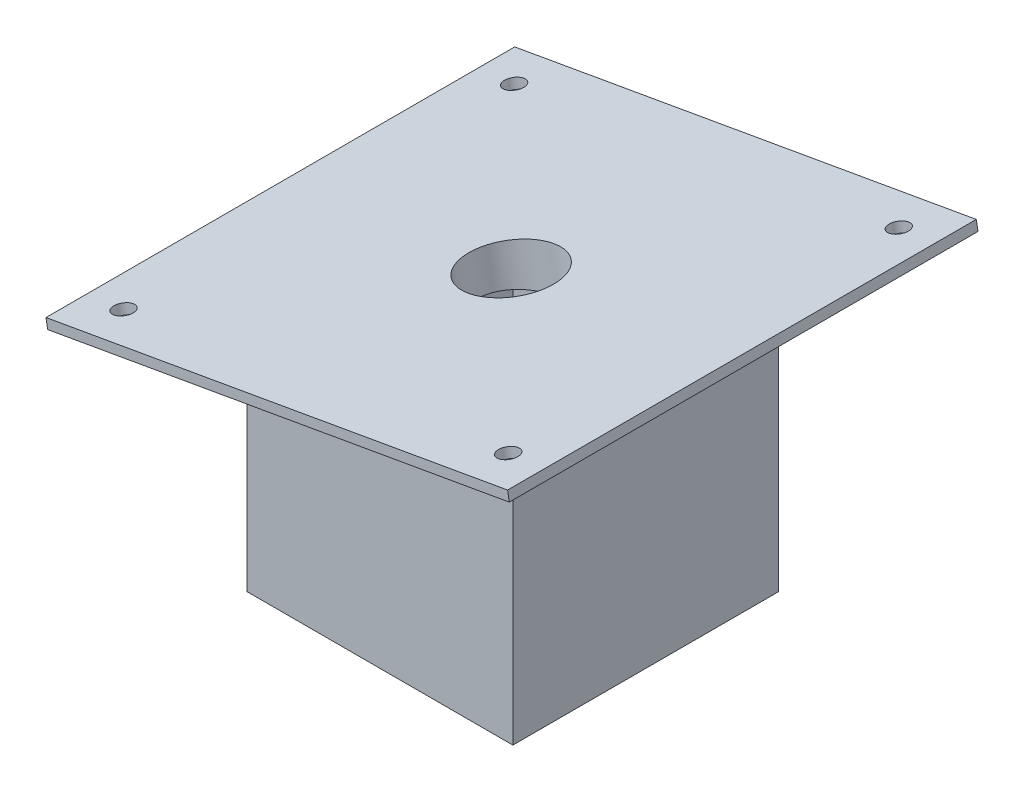
from build123d import *

# Parameters (mm, degrees)
SKETCH1_W                       = 86.36
SKETCH1_H                       = 86.36
BOSS_EXTRUDE1_DEPTH             = 95.25
SKETCH2_W                       = 78.74
SKETCH2_H                       = 78.74
CUT_EXTRUDE1_DEPTH              = 76.2
CUT_EXTRUDE2_DEPTH              = 87.36
SKETCH7_W                       = 152.4
SKETCH7_H                       = 152.4
BOSS_EXTRUDE2_DEPTH             = 3.175
SKETCH9_R                       = 13.97
CUT_EXTRUDE4_DEPTH              = 103.510777623
F_1_4_0_25_DIAMETER_HOLE1_D     = 6.35
F_1_4_0_25_DIAMETER_HOLE1_DEPTH = 3.175
F_1_4_0_25_DIAMETER_HOLE1_TIP   = 1.907732465


with BuildPart() as part:
    # Sketch1 → Boss-Extrude1 (new body)
    with BuildSketch(Plane(origin=(0, 0, 0), x_dir=(1, 0, 0), z_dir=(0, 1, 0))):
        Rectangle(SKETCH1_W, SKETCH1_H)
    extrude(amount=BOSS_EXTRUDE1_DEPTH)

    # Sketch2 → Cut-Extrude1 (cut)
    with BuildSketch(Plane(origin=(0, 0, 0), x_dir=(-1, 0, 0), z_dir=(0, -1, 0))):
        Rectangle(SKETCH2_W, SKETCH2_H)
    extrude(amount=-CUT_EXTRUDE1_DEPTH, mode=Mode.SUBTRACT)

    # Sketch4 → Cut-Extrude2 (cut, through all)
    with BuildSketch(Plane(origin=(0, 0, -43.18), x_dir=(-1, 0, 0), z_dir=(0, 0, -1))):
        Polygon((-43.18, 95.25), (43.18, 80.022401946), (43.18, 95.25), align=None)
    extrude(amount=-CUT_EXTRUDE2_DEPTH, mode=Mode.SUBTRACT)

    # Sketch7 → Boss-Extrude2 (add)
    with BuildSketch(Plane(origin=(-14.986673009, 84.993646171, 0), x_dir=(0.984807753, 0.173648178, 0), z_dir=(-0.173648178, 0.984807753, 0))):
        with Locations((15.217866597, 0)):
            Rectangle(SKETCH7_W, SKETCH7_H)
    extrude(amount=BOSS_EXTRUDE2_DEPTH)

    # Sketch9 → Cut-Extrude4 (cut, through all)
    with BuildSketch(Plane(origin=(-15.538005973, 88.120410786, 0), x_dir=(0.984807753, 0.173648178, 0), z_dir=(-0.173648178, 0.984807753, 0))):
        with Locations((15.217866597, 0)):
            Circle(SKETCH9_R)
    extrude(amount=-CUT_EXTRUDE4_DEPTH, mode=Mode.SUBTRACT)

    # 1/4 (0.25) Diameter Hole1
    with Locations(Plane(origin=(-15.538005973, 88.120410786, 0), x_dir=(0.984807753, 0.173648178, 0), z_dir=(-0.173648178, 0.984807753, 0))):
        with Locations((-48.282133403, 63.5), (78.717866597, 63.5), (78.717866597, -63.5), (-48.282133403, -63.5)):
            Hole(F_1_4_0_25_DIAMETER_HOLE1_D / 2, depth=F_1_4_0_25_DIAMETER_HOLE1_DEPTH)
            with Locations((0, 0, -(F_1_4_0_25_DIAMETER_HOLE1_DEPTH + F_1_4_0_25_DIAMETER_HOLE1_TIP / 2))):  # 118° drill point
                Cone(0, F_1_4_0_25_DIAMETER_HOLE1_D / 2, F_1_4_0_25_DIAMETER_HOLE1_TIP, mode=Mode.SUBTRACT)


solid = part.part
